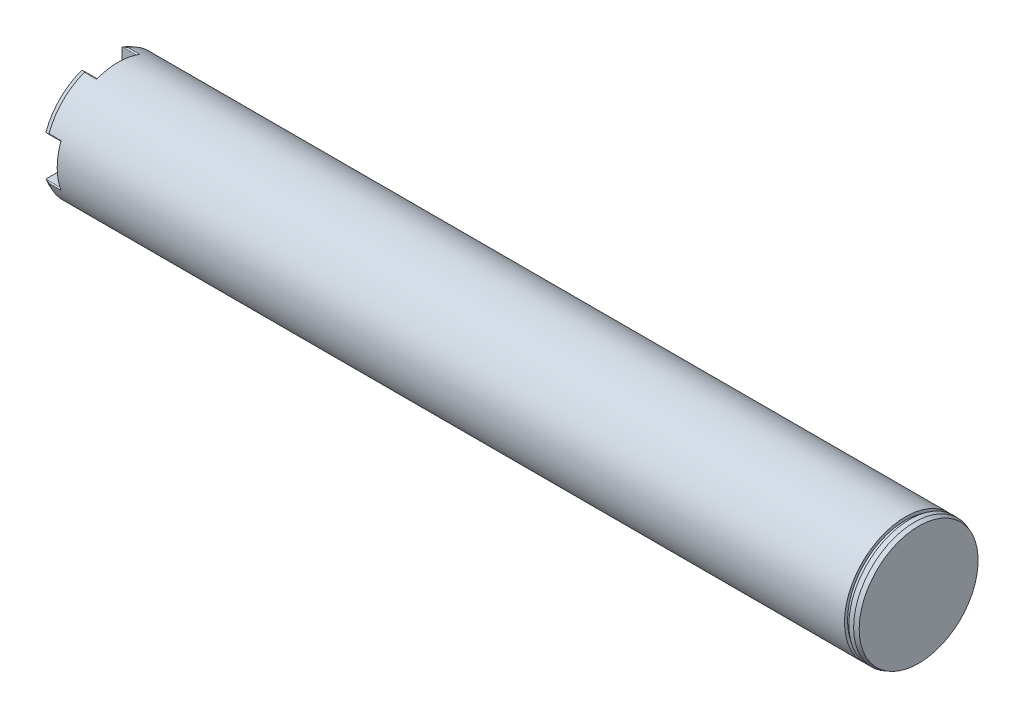
from build123d import *

# Parameters (mm, degrees)
AFFR_SNING_DEPTH = 8
R0_5_RUNDINGER_R = 0.5


with BuildPart() as part:
    # Sketch1 → Base-Revolve (revolve)
    with BuildSketch(Plane.XY):
        Polygon((-201, 20), (-201, 29.272059531), (-199, 30), (0, 30), (194.5, 30), (194.5, 28.5), (196.65, 28.5), (196.65, 30), (199, 30), (201, 29.272059531), (201, 0), (-146.793975667, 0), (-151, 7), (-182.098709071, 7), (-183, 8.5), (-193, 8.5), (-193, 20), align=None)
    revolve(axis=Axis((-283, 0, 0), (1, 0, 0)))

    # Sketch3 → Affræsning (cut)
    with BuildSketch(Plane.ZY.offset(201)):
        with BuildLine():
            Line((10, 28.284271247), (10, 17.320508076))
            ThreePointArc((10, 17.320508076), (0, 20), (-10, 17.320508076))
            Line((-10, 17.320508076), (-10, 28.284271247))
            ThreePointArc((-10, 28.284271247), (0, 30), (10, 28.284271247))
        make_face()
        with BuildLine():
            Line((17.320508076, 10), (28.284271247, 10))
            ThreePointArc((28.284271247, 10), (30, 0), (28.284271247, -10))
            Line((28.284271247, -10), (17.320508076, -10))
            ThreePointArc((17.320508076, -10), (20, 0), (17.320508076, 10))
        make_face()
        with BuildLine():
            Line((-17.320508076, -10), (-28.284271247, -10))
            ThreePointArc((-28.284271247, -10), (-30, 0), (-28.284271247, 10))
            Line((-28.284271247, 10), (-17.320508076, 10))
            ThreePointArc((-17.320508076, 10), (-20, 0), (-17.320508076, -10))
        make_face()
        with BuildLine():
            Line((-10, -28.284271247), (-10, -17.320508076))
            ThreePointArc((-10, -17.320508076), (0, -20), (10, -17.320508076))
            Line((10, -17.320508076), (10, -28.284271247))
            ThreePointArc((10, -28.284271247), (0, -30), (-10, -28.284271247))
        make_face()
    extrude(amount=-AFFR_SNING_DEPTH, mode=Mode.SUBTRACT)

    # R0.5 rundinger
    r0_5_rundinger_edges = [part.edges().sort_by_distance(p)[0] for p in [
        (-196, 28.284271247, -10),
        (-196, 28.284271247, 10),
        (-197, 17.320508076, 10),
        (-197, 17.320508076, -10),
        (-197, -10, 17.320508076),
        (-197, 10, 17.320508076),
        (-196, 10, 28.284271247),
        (-196, -10, 28.284271247),
        (-197, 10, -17.320508076),
        (-197, -10, -17.320508076),
        (-196, -10, -28.284271247),
        (-196, 10, -28.284271247),
        (-196, -28.284271247, 10),
        (-196, -28.284271247, -10),
        (-197, -17.320508076, -10),
        (-197, -17.320508076, 10),
    ]]
    fillet(r0_5_rundinger_edges, radius=R0_5_RUNDINGER_R)


solid = part.part
